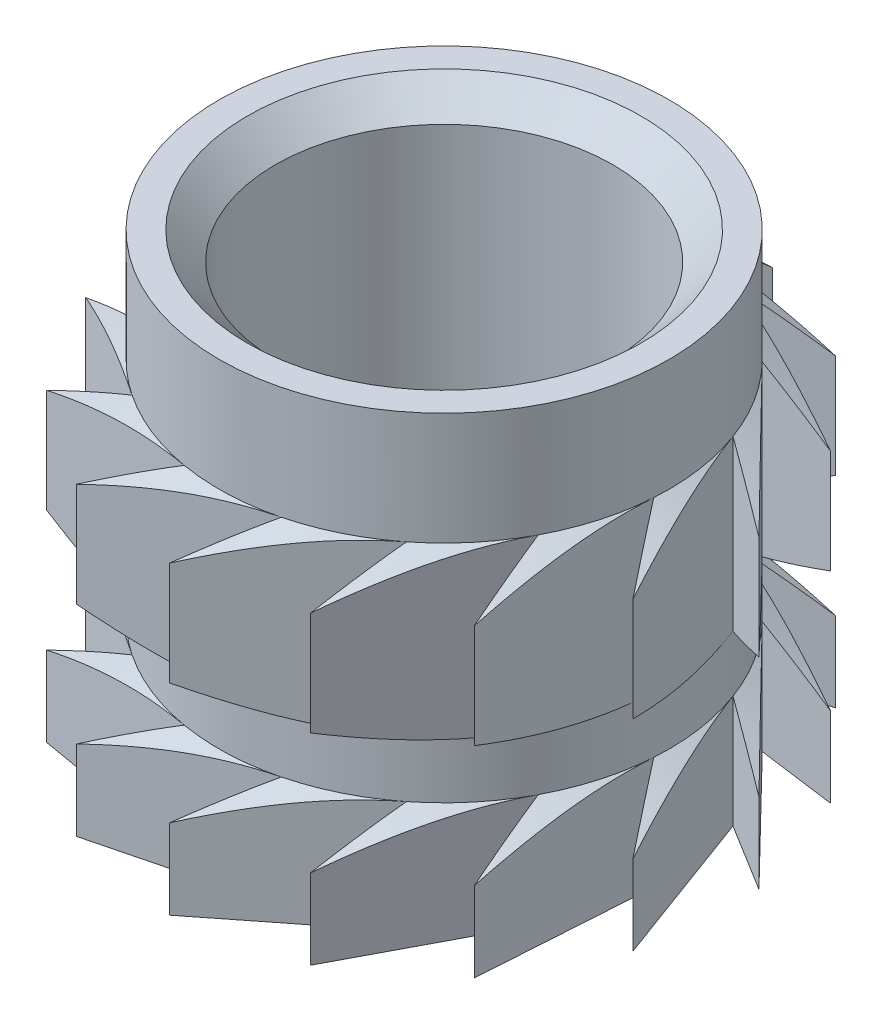
from build123d import *

# Parameters (mm, degrees)
SKETCH1_R           = 2
SKETCH1_R_2         = 1.5
BOSS_EXTRUDE1_DEPTH = 4
CUT_EXTRUDE3_DEPTH  = 5
CHAMFER1_SIZE       = 0.25


with BuildPart() as part:
    # Sketch1 → Boss-Extrude1 (new body)
    with BuildSketch(Plane(origin=(0, 0, 0), x_dir=(1, 0, 0), z_dir=(0, 1, 0))):
        Circle(SKETCH1_R)
        Circle(SKETCH1_R_2, mode=Mode.SUBTRACT)
    extrude(amount=BOSS_EXTRUDE1_DEPTH)

    # Sketch2 → Revolve1 (revolve)
    with BuildSketch(Plane.XY):
        Polygon((2, 3), (2.5, 2.711324865), (2.5, 1.788675135), (2, 1.5), align=None)
        Polygon((2, 0), (2.5, 0), (2.5, 0.711324865), (2, 1), align=None)
    revolve(axis=Axis((0, 0, 0), (0, 1, 0)))

    # Sketch3 → Cut-Extrude3 (cut, through all)
    with BuildSketch(Plane(origin=(0, 4, 0), x_dir=(1, 0, 0), z_dir=(0, 1, 0))):
        with BuildLine():
            Line((-0.883481791, 1.794285352), (0.462232224, 2.456896695))
            ThreePointArc((0.462232224, 2.456896695), (-0.058686206, 2.499311091), (-0.577039766, 2.432493599))
            Line((-0.577039766, 2.432493599), (-0.883481791, 1.794285352))
        make_face()
        with BuildLine():
            Line((0.462232224, 2.456896695), (-0.077299176, 1.998505651))
            Line((-0.077299176, 1.998505651), (1.421580063, 2.056480033))
            ThreePointArc((1.421580063, 2.056480033), (0.962948887, 2.307104125), (0.462232224, 2.456896695))
        make_face()
        with BuildLine():
            ThreePointArc((2.135123794, 1.30047929), (1.818081368, 1.715977896), (1.421580063, 2.056480033))
            Line((1.421580063, 2.056480033), (0.742249169, 1.857166167))
            Line((0.742249169, 1.857166167), (2.135123794, 1.30047929))
        make_face()
        with BuildLine():
            ThreePointArc((2.479485224, 0.319613864), (2.358851064, 0.8281435), (2.135123794, 1.30047929))
            Line((2.135123794, 1.30047929), (1.433455889, 1.394705781))
            Line((1.433455889, 1.394705781), (2.479485224, 0.319613864))
        make_face()
        with BuildLine():
            ThreePointArc((2.5, 0), (2.494866035, 0.160135785), (2.479485224, 0.319613864))
            Line((2.479485224, 0.319613864), (1.876805063, 0.691088094))
            Line((1.876805063, 0.691088094), (2.395121134, -0.716515703))
            ThreePointArc((2.395121134, -0.716515703), (2.473641328, -0.362075382), (2.5, 0))
        make_face()
        with BuildLine():
            ThreePointArc((1.896618841, -1.628753196), (2.193809999, -1.198831801), (2.395121134, -0.716515703))
            Line((2.395121134, -0.716515703), (1.995637592, -0.132025002))
            Line((1.995637592, -0.132025002), (1.896618841, -1.628753196))
        make_face()
        with BuildLine():
            ThreePointArc((1.07017392, -2.259364464), (1.516536338, -1.987490261), (1.896618841, -1.628753196))
            Line((1.896618841, -1.628753196), (1.769406251, -0.932309776))
            Line((1.769406251, -0.932309776), (1.07017392, -2.259364464))
        make_face()
        with BuildLine():
            ThreePointArc((0.058686206, -2.499311091), (0.577039766, -2.432493599), (1.07017392, -2.259364464))
            Line((1.07017392, -2.259364464), (1.237228495, -1.57138972))
            Line((1.237228495, -1.57138972), (0.058686206, -2.499311091))
        make_face()
        with BuildLine():
            ThreePointArc((-0.962948887, -2.307104125), (-0.462232224, -2.456896695), (0.058686206, -2.499311091))
            Line((0.058686206, -2.499311091), (0.491122692, -1.938762105))
            Line((0.491122692, -1.938762105), (-0.962948887, -2.307104125))
        make_face()
        with BuildLine():
            Line((-0.339902686, -1.97090491), (-1.818081368, -1.715977896))
            ThreePointArc((-1.818081368, -1.715977896), (-1.421580063, -2.056480033), (-0.962948887, -2.307104125))
            Line((-0.962948887, -2.307104125), (-0.339902686, -1.97090491))
        make_face()
        with BuildLine():
            Line((-1.112155801, -1.662260351), (-2.358851064, -0.8281435))
            ThreePointArc((-2.358851064, -0.8281435), (-2.135123794, -1.30047929), (-1.818081368, -1.715977896))
            Line((-1.818081368, -1.715977896), (-1.112155801, -1.662260351))
        make_face()
        with BuildLine():
            Line((-1.692107076, -1.066195875), (-2.491753982, 0.202884431))
            ThreePointArc((-2.491753982, 0.202884431), (-2.479485224, -0.319613864), (-2.358851064, -0.8281435))
            Line((-2.358851064, -0.8281435), (-1.692107076, -1.066195875))
        make_face()
        with BuildLine():
            Line((-1.979477664, -0.285776447), (-2.193809999, 1.198831801))
            ThreePointArc((-2.193809999, 1.198831801), (-2.395121134, 0.716515703), (-2.491753982, 0.202884431))
            Line((-2.491753982, 0.202884431), (-1.979477664, -0.285776447))
        make_face()
        with BuildLine():
            Line((-1.924578581, 0.544056325), (-1.516536338, 1.987490261))
            ThreePointArc((-1.516536338, 1.987490261), (-1.896618841, 1.628753196), (-2.193809999, 1.198831801))
            Line((-2.193809999, 1.198831801), (-1.924578581, 0.544056325))
        make_face()
        with BuildLine():
            Line((-1.536902378, 1.279816816), (-0.577039766, 2.432493599))
            ThreePointArc((-0.577039766, 2.432493599), (-1.07017392, 2.259364464), (-1.516536338, 1.987490261))
            Line((-1.516536338, 1.987490261), (-1.536902378, 1.279816816))
        make_face()
    extrude(amount=-CUT_EXTRUDE3_DEPTH, mode=Mode.SUBTRACT)

    # Chamfer1
    chamfer1_edges = [part.edges().sort_by_distance(p)[0] for p in [
        (-1.5, 0, 0),
        (-1.5, 4, 0),
    ]]
    chamfer(chamfer1_edges, length=CHAMFER1_SIZE)


solid = part.part
